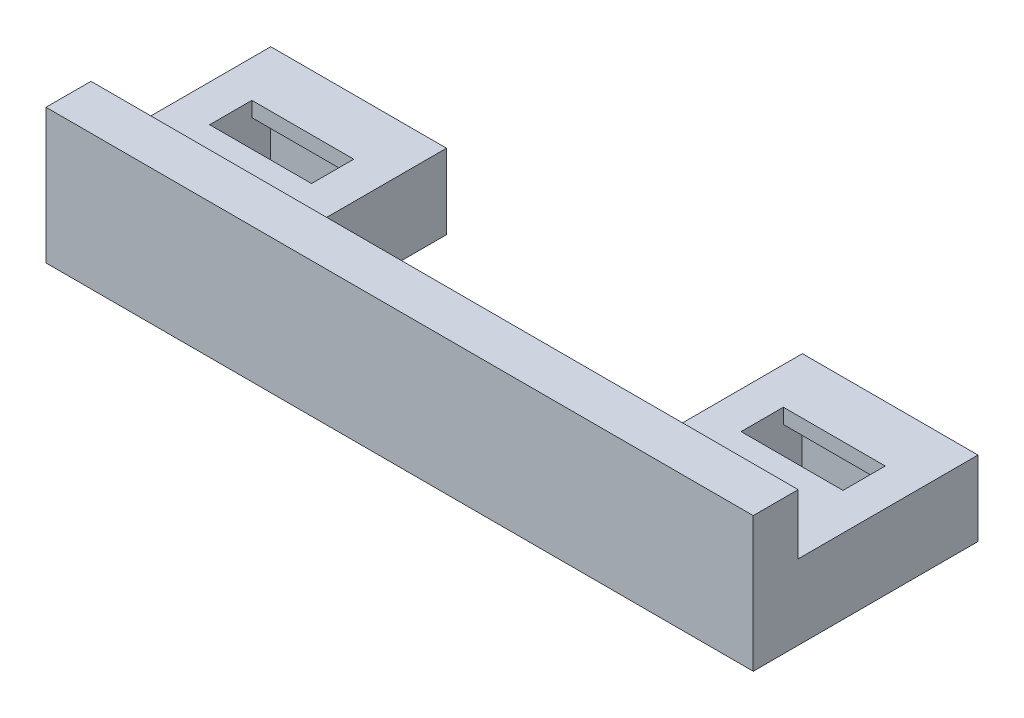
from build123d import *

# Parameters (mm, degrees)
SKETCH1_W           = 59.944
SKETCH1_H           = 19.05
SKETCH1_W_2         = 8.636
SKETCH1_H_2         = 6.7564
BOSS_EXTRUDE1_DEPTH = 5.08
SKETCH2_W           = 59.944
SKETCH2_H           = 19.05
SKETCH2_W_2         = 8.636
SKETCH2_H_2         = 3.5814
BOSS_EXTRUDE2_DEPTH = 1.27
SKETCH5_W           = 30.1625
SKETCH5_H           = 13.0302
CUT_EXTRUDE1_DEPTH  = 30.48
SKETCH6_W           = 59.944
SKETCH6_H           = 3.81
BOSS_EXTRUDE4_DEPTH = 5.08


with BuildPart() as part:
    # Sketch1 → Boss-Extrude1 (new body)
    with BuildSketch(Plane(origin=(0, 0, 0), x_dir=(1, 0, 0), z_dir=(0, 1, 0))):
        with Locations((-29.450443736, 19.033631364)):
            Rectangle(SKETCH1_W, SKETCH1_H)
        with Locations((-51.967543736, 22.030831364)):
            Rectangle(SKETCH1_W_2, SKETCH1_H_2, mode=Mode.SUBTRACT)
        with Locations((-6.920643736, 22.030831364)):
            Rectangle(SKETCH1_W_2, SKETCH1_H_2, mode=Mode.SUBTRACT)
    extrude(amount=BOSS_EXTRUDE1_DEPTH)

    # Sketch2 → Boss-Extrude2 (add)
    with BuildSketch(Plane(origin=(0, 5.08, 0), x_dir=(1, 0, 0), z_dir=(0, 1, 0))):
        with Locations((-29.450443736, 19.033631364)):
            Rectangle(SKETCH2_W, SKETCH2_H)
        with Locations((-51.967543736, 22.030831364)):
            Rectangle(SKETCH2_W_2, SKETCH2_H_2, mode=Mode.SUBTRACT)
        with Locations((-6.920643736, 22.030831364)):
            Rectangle(SKETCH2_W_2, SKETCH2_H_2, mode=Mode.SUBTRACT)
    extrude(amount=BOSS_EXTRUDE2_DEPTH)

    # Sketch5 → Cut-Extrude1 (cut)
    with BuildSketch(Plane.XZ):
        with Locations((-29.444093736, -22.043531364)):
            Rectangle(SKETCH5_W, SKETCH5_H)
    extrude(amount=-CUT_EXTRUDE1_DEPTH, mode=Mode.SUBTRACT)

    # Sketch6 → Boss-Extrude4 (add)
    with BuildSketch(Plane(origin=(0, 6.35, 0), x_dir=(1, 0, 0), z_dir=(0, 1, 0))):
        with Locations((-29.450443736, 11.413631364)):
            Rectangle(SKETCH6_W, SKETCH6_H)
    extrude(amount=BOSS_EXTRUDE4_DEPTH)


solid = part.part
